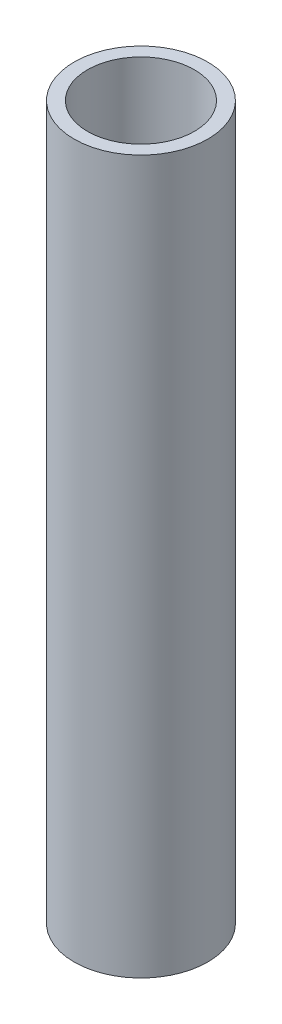
from build123d import *

# Parameters (mm, degrees)
SKETCH1_R           = 4.7625
SKETCH1_R_2         = 3.81
BOSS_EXTRUDE1_DEPTH = 50.8


with BuildPart() as part:
    # Sketch1 → Boss-Extrude1 (new body)
    with BuildSketch(Plane(origin=(0, 0, 0), x_dir=(1, 0, 0), z_dir=(0, 1, 0))):
        Circle(SKETCH1_R)
        Circle(SKETCH1_R_2, mode=Mode.SUBTRACT)
    extrude(amount=BOSS_EXTRUDE1_DEPTH)


solid = part.part
